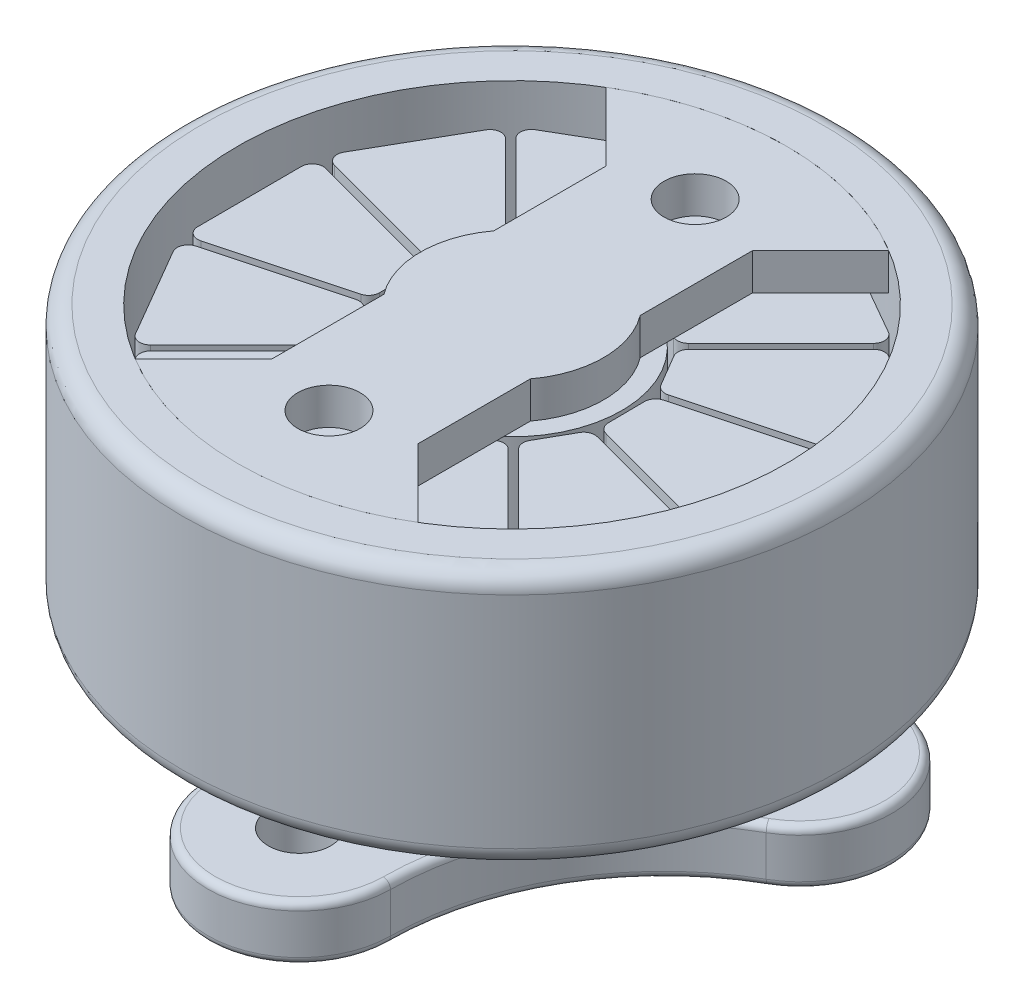
from build123d import *

# Parameters (mm, degrees)
SKETCH_1_R          = 9
EXTRUDE_1_DEPTH     = 7
SKETCH_2_R          = 3
EXTRUDE_2_DEPTH     = 2.5
EXTRUDE_3_DEPTH     = 1.5
CUT_EXTRUDE_1_REACH = 13
SKETCH_4_R          = 0.85
FILLET_1_R          = 0.5
FILLET_5_R          = 0.2
SKETCH_5_R          = 7.5
CUT_EXTRUDE_2_DEPTH = 7
EXTRUDE_6_DEPTH     = 1
SKETCH_8_R          = 3
EXTRUDE_5_DEPTH     = 6
SKETCH_7_R          = 0.85
CUT_EXTRUDE_4_DEPTH = 1
EXTRUDE_8_DEPTH     = 6
EXTRUDE_8_2_DEPTH   = 6
EXTRUDE_8_3_DEPTH   = 6
EXTRUDE_8_4_DEPTH   = 6
EXTRUDE_8_5_DEPTH   = 6
EXTRUDE_8_6_DEPTH   = 6
EXTRUDE_8_7_DEPTH   = 6
EXTRUDE_8_8_DEPTH   = 6
EXTRUDE_8_9_DEPTH   = 6
EXTRUDE_8_10_DEPTH  = 6
EXTRUDE_8_11_DEPTH  = 6
EXTRUDE_8_12_DEPTH  = 6


with BuildPart() as part:
    # 草图1 → 凸台-拉伸1 (new body)
    with BuildSketch(Plane(origin=(0, 0, 0), x_dir=(1, 0, 0), z_dir=(0, 1, 0))):
        Circle(SKETCH_1_R)
    extrude(amount=EXTRUDE_1_DEPTH)

    # 草图2 → 凸台-拉伸2 (add)
    with BuildSketch(Plane.XZ):
        Circle(SKETCH_2_R)
    extrude(amount=EXTRUDE_2_DEPTH)

    # 草图3 → 凸台-拉伸3 (add)
    with BuildSketch(Plane.XZ.offset(2.5)):
        with BuildLine():
            ThreePointArc((-6.245897858, -0.756368478), (-3.515987299, 2.004017438), (-2.532008362, 5.759537046))
            ThreePointArc((-2.532008362, 5.759537046), (-0.045923579, 8.273375237), (2.467914612, 5.787290454))
            ThreePointArc((2.467914612, 5.787290454), (3.49352366, 2.042925601), (6.253909577, -0.686984959))
            ThreePointArc((6.253909577, -0.686984959), (7.18791492, -4.096916633), (3.777983246, -5.030921976))
            ThreePointArc((3.777983246, -5.030921976), (0.022463638, -4.046943039), (-3.721901215, -5.072552087))
            ThreePointArc((-3.721901215, -5.072552087), (-7.141991341, -4.176458604), (-6.245897858, -0.756368478))
        make_face()
    extrude(amount=EXTRUDE_3_DEPTH)

    # 草图4 → 切除-拉伸1 (cut, up to next)
    with BuildSketch(Plane.XZ.offset(4), mode=Mode.PRIVATE) as cut_extrude_1_sk1:
        with Locations((-0.032046875, 5.77341375)):
            Circle(SKETCH_4_R)
    cut_extrude_1_tool1 = extrude(cut_extrude_1_sk1.sketch, amount=-CUT_EXTRUDE_1_REACH, mode=Mode.PRIVATE) & part.part
    add(cut_extrude_1_tool1.solids().sort_by_distance((-0.032047, -4, 5.773414))[0], mode=Mode.SUBTRACT)
    # 草图4 → 切除-拉伸1 (cut, up to next)
    with BuildSketch(Plane.XZ.offset(4), mode=Mode.PRIVATE) as cut_extrude_1_sk2:
        with Locations((5.015946412, -2.858953467)):
            Circle(SKETCH_4_R)
    cut_extrude_1_tool2 = extrude(cut_extrude_1_sk2.sketch, amount=-CUT_EXTRUDE_1_REACH, mode=Mode.PRIVATE) & part.part
    add(cut_extrude_1_tool2.solids().sort_by_distance((5.015946, -4, -2.858953))[0], mode=Mode.SUBTRACT)
    # 草图4 → 切除-拉伸1 (cut, up to next)
    with BuildSketch(Plane.XZ.offset(4), mode=Mode.PRIVATE) as cut_extrude_1_sk3:
        with Locations((-4.983899537, -2.914460283)):
            Circle(SKETCH_4_R)
    cut_extrude_1_tool3 = extrude(cut_extrude_1_sk3.sketch, amount=-CUT_EXTRUDE_1_REACH, mode=Mode.PRIVATE) & part.part
    add(cut_extrude_1_tool3.solids().sort_by_distance((-4.9839, -4, -2.91446))[0], mode=Mode.SUBTRACT)

    # 圆角1
    fillet_1_edges = [part.edges().sort_by_distance(p)[0] for p in [
        (-9, 0, 0),
        (-9, 7, 0),
    ]]
    fillet(fillet_1_edges, radius=FILLET_1_R)

    # 圆角5
    fillet_5_edges = [part.edges().sort_by_distance(p)[0] for p in [
        (0.022463638, -2.5, -4.046943039),
        (7.18791492, -2.5, -4.096916633),
        (3.49352366, -2.5, 2.042925601),
        (-0.045923579, -2.5, 8.273375237),
        (-3.515987299, -2.5, 2.004017438),
        (-7.141991341, -2.5, -4.176458604),
        (0.022463638, -4, -4.046943039),
        (7.18791492, -4, -4.096916633),
        (3.49352366, -4, 2.042925601),
        (-0.045923579, -4, 8.273375237),
        (-3.515987299, -4, 2.004017438),
        (-7.141991341, -4, -4.176458604),
    ]]
    fillet(fillet_5_edges, radius=FILLET_5_R)

    # 草图5 → 切除-拉伸2 (cut)
    with BuildSketch(Plane(origin=(0, 7, 0), x_dir=(1, 0, 0), z_dir=(0, 1, 0))):
        Circle(SKETCH_5_R)
    extrude(amount=-CUT_EXTRUDE_2_DEPTH, mode=Mode.SUBTRACT)

    # 草图8 → 凸台-拉伸5 (add)
    with BuildSketch(Plane(origin=(0, 0, 0), x_dir=(1, 0, 0), z_dir=(0, 1, 0))):
        Circle(SKETCH_8_R)
    extrude(amount=EXTRUDE_5_DEPTH)


with BuildPart() as body_2:
    # 草图6 → 凸台-拉伸6 (new body)
    with BuildSketch(Plane(origin=(0, 7, 0), x_dir=(1, 0, 0), z_dir=(0, 1, 0))):
        with BuildLine():
            ThreePointArc((-2, 1.5), (-2.5, 0), (-2, -1.5))
            Line((-2, -1.5), (-2, 1.5))
        make_face()
        with BuildLine():
            ThreePointArc((-2, -1.5), (-1.118033989, -2.236067977), (0, -2.5))
            Line((0, -2.5), (0, 2.5))
            ThreePointArc((0, 2.5), (-1.118033989, 2.236067977), (-2, 1.5))
            Line((-2, 1.5), (-2, -1.5))
        make_face()
        with BuildLine():
            Line((0, 2.5), (0, -2.5))
            ThreePointArc((0, -2.5), (1.118033989, -2.236067977), (2, -1.5))
            Line((2, -1.5), (2, 1.5))
            ThreePointArc((2, 1.5), (1.118033989, 2.236067977), (0, 2.5))
        make_face()
        with BuildLine():
            Line((2, 1.5), (2, -1.5))
            ThreePointArc((2, -1.5), (2.371708245, -0.790569415), (2.5, 0))
            ThreePointArc((2.5, 0), (2.371708245, 0.790569415), (2, 1.5))
        make_face()
        with BuildLine():
            ThreePointArc((-2, -7.228416147), (-1.009177609, -7.431793899), (0, -7.5))
            Line((0, -7.5), (0, -2.5))
            ThreePointArc((0, -2.5), (-1.118033989, -2.236067977), (-2, -1.5))
            Line((-2, -1.5), (-2, -4.571428571))
            Line((-2, -4.571428571), (-2, -7.228416147))
        make_face()
        with BuildLine():
            ThreePointArc((-2, 1.5), (-1.118033989, 2.236067977), (0, 2.5))
            Line((0, 2.5), (0, 7.5))
            ThreePointArc((0, 7.5), (-1.009177609, 7.431793899), (-2, 7.228416147))
            Line((-2, 7.228416147), (-2, 4.571428571))
            Line((-2, 4.571428571), (-2, 1.5))
        make_face()
        with BuildLine():
            ThreePointArc((-3.859374516, -6.430803087), (-2.956706627, -6.892596457), (-2, -7.228416147))
            Line((-2, -7.228416147), (-2, -4.571428571))
            Line((-2, -4.571428571), (-3.859374516, -6.430803087))
        make_face()
        with BuildLine():
            Line((0, -2.5), (0, -7.5))
            ThreePointArc((0, -7.5), (1.009177609, -7.431793899), (2, -7.228416147))
            Line((2, -7.228416147), (2, -4.571428571))
            Line((2, -4.571428571), (2, -1.5))
            ThreePointArc((2, -1.5), (1.118033989, -2.236067977), (0, -2.5))
        make_face()
        with BuildLine():
            Line((0, 7.5), (0, 2.5))
            ThreePointArc((0, 2.5), (1.118033989, 2.236067977), (2, 1.5))
            Line((2, 1.5), (2, 4.571428571))
            Line((2, 4.571428571), (2, 7.228416147))
            ThreePointArc((2, 7.228416147), (1.009177609, 7.431793899), (0, 7.5))
        make_face()
        with BuildLine():
            Line((2, -4.571428571), (2, -7.228416147))
            ThreePointArc((2, -7.228416147), (2.956706627, -6.892596457), (3.859374516, -6.430803087))
            Line((3.859374516, -6.430803087), (2, -4.571428571))
        make_face()
        with BuildLine():
            ThreePointArc((-2, 7.228416147), (-2.956706627, 6.892596457), (-3.859374516, 6.430803087))
            Line((-3.859374516, 6.430803087), (-2, 4.571428571))
            Line((-2, 4.571428571), (-2, 7.228416147))
        make_face()
        with BuildLine():
            ThreePointArc((3.859374516, 6.430803087), (2.956706627, 6.892596457), (2, 7.228416147))
            Line((2, 7.228416147), (2, 4.571428571))
            Line((2, 4.571428571), (3.859374516, 6.430803087))
        make_face()
    extrude(amount=-EXTRUDE_6_DEPTH)

    # 草图7 → 切除-拉伸4 (cut)
    with BuildSketch(Plane(origin=(0, 7, 0), x_dir=(1, 0, 0), z_dir=(0, 1, 0))):
        with Locations((0, 5)):
            Circle(SKETCH_7_R)
        with Locations((0, -5)):
            Circle(SKETCH_7_R)
    extrude(amount=-CUT_EXTRUDE_4_DEPTH, mode=Mode.SUBTRACT)


with BuildPart() as body_3:
    # 草图12 → 凸台-拉伸8 (new body)
    with BuildSketch(Plane.XZ):
        with BuildLine():
            Line((-1.392977324, 7.149356995), (1.446702107, 7.139429898))
            ThreePointArc((1.446702107, 7.139429898), (1.683978216, 7.021643866), (1.735431106, 6.761786017))
            Line((1.735431106, 6.761786017), (0.812687766, 3.318060992))
            ThreePointArc((0.812687766, 3.318060992), (0.704532214, 3.156931962), (0.520377484, 3.095717395))
            Line((0.520377484, 3.095717395), (-0.473403291, 3.104106974))
            ThreePointArc((-0.473403291, 3.104106974), (-0.654502165, 3.166863264), (-0.760648505, 3.326450571))
            Line((-0.760648505, 3.326450571), (-1.683803821, 6.771713114))
            ThreePointArc((-1.683803821, 6.771713114), (-1.631712493, 7.032402992), (-1.392977324, 7.149356995))
        make_face()
    extrude(amount=-EXTRUDE_8_DEPTH)


with BuildPart() as body_4:
    # 草图12 → Extrude 8 2 (new body)
    with BuildSketch(Plane.XZ):
        with BuildLine():
            Line((2.368324747, 6.88801344), (4.822595725, 5.459576607))
            ThreePointArc((4.822595725, 5.459576607), (4.969189847, 5.238932856), (4.883820433, 4.988162913))
            Line((4.883820433, 4.988162913), (2.362838747, 2.467181227))
            ThreePointArc((2.362838747, 2.467181227), (2.188608776, 2.38171717), (1.998518818, 2.420781165))
            Line((1.998518818, 2.420781165), (1.14207421, 2.924937141))
            ThreePointArc((1.14207421, 2.924937141), (1.01661613, 3.069835119), (1.004484357, 3.261114951))
            Line((1.004484357, 3.261114951), (1.927639673, 6.706377495))
            ThreePointArc((1.927639673, 6.706377495), (2.103097026, 6.906095887), (2.368324747, 6.88801344))
        make_face()
    extrude(amount=-EXTRUDE_8_2_DEPTH)


with BuildPart() as body_5:
    # 草图12 → Extrude 8 3 (new body)
    with BuildSketch(Plane.XZ):
        with BuildLine():
            Line((5.495036116, 4.781032247), (6.906278713, 2.316834173))
            ThreePointArc((6.906278713, 2.316834173), (6.922911072, 2.052454019), (6.723594019, 1.877965585))
            Line((6.723594019, 1.877965585), (3.279868993, 0.955222245))
            ThreePointArc((3.279868993, 0.955222245), (3.086249384, 0.968323186), (2.941158649, 1.097198577))
            Line((2.941158649, 1.097198577), (2.45153385, 1.962032764))
            ThreePointArc((2.45153385, 1.962032764), (2.415332954, 2.150247134), (2.500466446, 2.321966214))
            Line((2.500466446, 2.321966214), (5.022573673, 4.844073441))
            ThreePointArc((5.022573673, 4.844073441), (5.274383395, 4.929305966), (5.495036116, 4.781032247))
        make_face()
    extrude(amount=-EXTRUDE_8_3_DEPTH)


with BuildPart() as body_6:
    # 草图12 → Extrude 8 4 (new body)
    with BuildSketch(Plane.XZ):
        with BuildLine():
            Line((7.149356995, 1.392977324), (7.139429898, -1.446702107))
            ThreePointArc((7.139429898, -1.446702107), (7.021643866, -1.683978216), (6.761786017, -1.735431106))
            Line((6.761786017, -1.735431106), (3.318060992, -0.812687766))
            ThreePointArc((3.318060992, -0.812687766), (3.156931962, -0.704532214), (3.095717395, -0.520377484))
            Line((3.095717395, -0.520377484), (3.104106974, 0.473403291))
            ThreePointArc((3.104106974, 0.473403291), (3.166863264, 0.654502165), (3.326450571, 0.760648505))
            Line((3.326450571, 0.760648505), (6.771713114, 1.683803821))
            ThreePointArc((6.771713114, 1.683803821), (7.032402992, 1.631712493), (7.149356995, 1.392977324))
        make_face()
    extrude(amount=-EXTRUDE_8_4_DEPTH)


with BuildPart() as body_7:
    # 草图12 → Extrude 8 5 (new body)
    with BuildSketch(Plane.XZ):
        with BuildLine():
            Line((6.88801344, -2.368324747), (5.459576607, -4.822595725))
            ThreePointArc((5.459576607, -4.822595725), (5.238932856, -4.969189847), (4.988162913, -4.883820433))
            Line((4.988162913, -4.883820433), (2.467181227, -2.362838747))
            ThreePointArc((2.467181227, -2.362838747), (2.38171717, -2.188608776), (2.420781165, -1.998518818))
            Line((2.420781165, -1.998518818), (2.924937141, -1.14207421))
            ThreePointArc((2.924937141, -1.14207421), (3.069835119, -1.01661613), (3.261114951, -1.004484357))
            Line((3.261114951, -1.004484357), (6.706377495, -1.927639673))
            ThreePointArc((6.706377495, -1.927639673), (6.906095887, -2.103097026), (6.88801344, -2.368324747))
        make_face()
    extrude(amount=-EXTRUDE_8_5_DEPTH)


with BuildPart() as body_8:
    # 草图12 → Extrude 8 6 (new body)
    with BuildSketch(Plane.XZ):
        with BuildLine():
            Line((4.781032247, -5.495036116), (2.316834173, -6.906278713))
            ThreePointArc((2.316834173, -6.906278713), (2.052454019, -6.922911072), (1.877965585, -6.723594019))
            Line((1.877965585, -6.723594019), (0.955222245, -3.279868993))
            ThreePointArc((0.955222245, -3.279868993), (0.968323186, -3.086249384), (1.097198577, -2.941158649))
            Line((1.097198577, -2.941158649), (1.962032764, -2.45153385))
            ThreePointArc((1.962032764, -2.45153385), (2.150247134, -2.415332954), (2.321966214, -2.500466446))
            Line((2.321966214, -2.500466446), (4.844073441, -5.022573673))
            ThreePointArc((4.844073441, -5.022573673), (4.929305966, -5.274383395), (4.781032247, -5.495036116))
        make_face()
    extrude(amount=-EXTRUDE_8_6_DEPTH)


with BuildPart() as body_9:
    # 草图12 → Extrude 8 7 (new body)
    with BuildSketch(Plane.XZ):
        with BuildLine():
            Line((1.392977324, -7.149356995), (-1.446702107, -7.139429898))
            ThreePointArc((-1.446702107, -7.139429898), (-1.683978216, -7.021643866), (-1.735431106, -6.761786017))
            Line((-1.735431106, -6.761786017), (-0.812687766, -3.318060992))
            ThreePointArc((-0.812687766, -3.318060992), (-0.704532214, -3.156931962), (-0.520377484, -3.095717395))
            Line((-0.520377484, -3.095717395), (0.473403291, -3.104106974))
            ThreePointArc((0.473403291, -3.104106974), (0.654502165, -3.166863264), (0.760648505, -3.326450571))
            Line((0.760648505, -3.326450571), (1.683803821, -6.771713114))
            ThreePointArc((1.683803821, -6.771713114), (1.631712493, -7.032402992), (1.392977324, -7.149356995))
        make_face()
    extrude(amount=-EXTRUDE_8_7_DEPTH)


with BuildPart() as body_10:
    # 草图12 → Extrude 8 8 (new body)
    with BuildSketch(Plane.XZ):
        with BuildLine():
            Line((-2.368324747, -6.88801344), (-4.822595725, -5.459576607))
            ThreePointArc((-4.822595725, -5.459576607), (-4.969189847, -5.238932856), (-4.883820433, -4.988162913))
            Line((-4.883820433, -4.988162913), (-2.362838747, -2.467181227))
            ThreePointArc((-2.362838747, -2.467181227), (-2.188608776, -2.38171717), (-1.998518818, -2.420781165))
            Line((-1.998518818, -2.420781165), (-1.14207421, -2.924937141))
            ThreePointArc((-1.14207421, -2.924937141), (-1.01661613, -3.069835119), (-1.004484357, -3.261114951))
            Line((-1.004484357, -3.261114951), (-1.927639673, -6.706377495))
            ThreePointArc((-1.927639673, -6.706377495), (-2.103097026, -6.906095887), (-2.368324747, -6.88801344))
        make_face()
    extrude(amount=-EXTRUDE_8_8_DEPTH)


with BuildPart() as body_11:
    # 草图12 → Extrude 8 9 (new body)
    with BuildSketch(Plane.XZ):
        with BuildLine():
            Line((-5.495036116, -4.781032247), (-6.906278713, -2.316834173))
            ThreePointArc((-6.906278713, -2.316834173), (-6.922911072, -2.052454019), (-6.723594019, -1.877965585))
            Line((-6.723594019, -1.877965585), (-3.279868993, -0.955222245))
            ThreePointArc((-3.279868993, -0.955222245), (-3.086249384, -0.968323186), (-2.941158649, -1.097198577))
            Line((-2.941158649, -1.097198577), (-2.45153385, -1.962032764))
            ThreePointArc((-2.45153385, -1.962032764), (-2.415332954, -2.150247134), (-2.500466446, -2.321966214))
            Line((-2.500466446, -2.321966214), (-5.022573673, -4.844073441))
            ThreePointArc((-5.022573673, -4.844073441), (-5.274383395, -4.929305966), (-5.495036116, -4.781032247))
        make_face()
    extrude(amount=-EXTRUDE_8_9_DEPTH)


with BuildPart() as body_12:
    # 草图12 → Extrude 8 10 (new body)
    with BuildSketch(Plane.XZ):
        with BuildLine():
            Line((-7.149356995, -1.392977324), (-7.139429898, 1.446702107))
            ThreePointArc((-7.139429898, 1.446702107), (-7.021643866, 1.683978216), (-6.761786017, 1.735431106))
            Line((-6.761786017, 1.735431106), (-3.318060992, 0.812687766))
            ThreePointArc((-3.318060992, 0.812687766), (-3.156931962, 0.704532214), (-3.095717395, 0.520377484))
            Line((-3.095717395, 0.520377484), (-3.104106974, -0.473403291))
            ThreePointArc((-3.104106974, -0.473403291), (-3.166863264, -0.654502165), (-3.326450571, -0.760648505))
            Line((-3.326450571, -0.760648505), (-6.771713114, -1.683803821))
            ThreePointArc((-6.771713114, -1.683803821), (-7.032402992, -1.631712493), (-7.149356995, -1.392977324))
        make_face()
    extrude(amount=-EXTRUDE_8_10_DEPTH)


with BuildPart() as body_13:
    # 草图12 → Extrude 8 11 (new body)
    with BuildSketch(Plane.XZ):
        with BuildLine():
            Line((-6.88801344, 2.368324747), (-5.459576607, 4.822595725))
            ThreePointArc((-5.459576607, 4.822595725), (-5.238932856, 4.969189847), (-4.988162913, 4.883820433))
            Line((-4.988162913, 4.883820433), (-2.467181227, 2.362838747))
            ThreePointArc((-2.467181227, 2.362838747), (-2.38171717, 2.188608776), (-2.420781165, 1.998518818))
            Line((-2.420781165, 1.998518818), (-2.924937141, 1.14207421))
            ThreePointArc((-2.924937141, 1.14207421), (-3.069835119, 1.01661613), (-3.261114951, 1.004484357))
            Line((-3.261114951, 1.004484357), (-6.706377495, 1.927639673))
            ThreePointArc((-6.706377495, 1.927639673), (-6.906095887, 2.103097026), (-6.88801344, 2.368324747))
        make_face()
    extrude(amount=-EXTRUDE_8_11_DEPTH)


with BuildPart() as body_14:
    # 草图12 → Extrude 8 12 (new body)
    with BuildSketch(Plane.XZ):
        with BuildLine():
            Line((-4.781032247, 5.495036116), (-2.316834173, 6.906278713))
            ThreePointArc((-2.316834173, 6.906278713), (-2.052454019, 6.922911072), (-1.877965585, 6.723594019))
            Line((-1.877965585, 6.723594019), (-0.955222245, 3.279868993))
            ThreePointArc((-0.955222245, 3.279868993), (-0.968323186, 3.086249384), (-1.097198577, 2.941158649))
            Line((-1.097198577, 2.941158649), (-1.962032764, 2.45153385))
            ThreePointArc((-1.962032764, 2.45153385), (-2.150247134, 2.415332954), (-2.321966214, 2.500466446))
            Line((-2.321966214, 2.500466446), (-4.844073441, 5.022573673))
            ThreePointArc((-4.844073441, 5.022573673), (-4.929305966, 5.274383395), (-4.781032247, 5.495036116))
        make_face()
    extrude(amount=-EXTRUDE_8_12_DEPTH)


solid = Compound([part.part, body_2.part, body_3.part, body_4.part, body_5.part, body_6.part, body_7.part, body_8.part, body_9.part, body_10.part, body_11.part, body_12.part, body_13.part, body_14.part])
